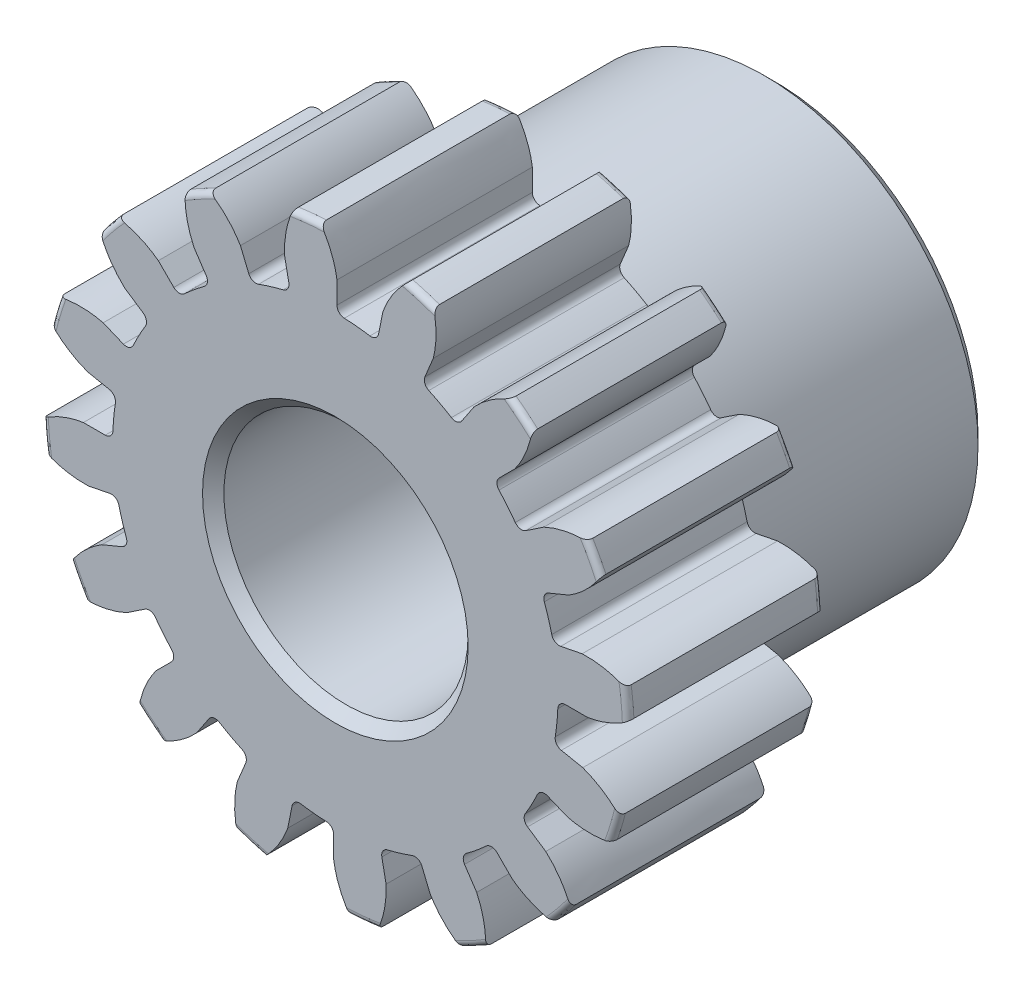
from build123d import *

# Parameters (mm, degrees)
SKETCH1_R                = 9.525
BOSS_EXTRUDE1_DEPTH      = 6.35
SKETCH2_W                = 7.9375
SKETCH2_H                = 6.9453125
FILLET2_R                = 0.1905
CUT_EXTRUDE1_DEPTH       = 15.2875
FILLET1_R                = 0.249115136
CIRPATTERN1_COUNT        = 16
FILLET1_OF_CIRPATTERN1_R = 0.249115136
SKETCH5_R                = 3.96875
CUT_EXTRUDE2_DEPTH       = 15.2875
CHAMFER1_SIZE            = 0.347265625


with BuildPart() as part:
    # Sketch1 → Boss-Extrude1 (new body)
    with BuildSketch(Plane.XY):
        Circle(SKETCH1_R)
    extrude(amount=-BOSS_EXTRUDE1_DEPTH)

    # Sketch2 → Revolve1 (revolve)
    with BuildSketch(Plane(origin=(0, 0, 0), x_dir=(0, 0, -1), z_dir=(1, 0, 0))):
        with Locations((10.31875, 3.47265625)):
            Rectangle(SKETCH2_W, SKETCH2_H)
    revolve(axis=Axis((0, 0, -6.35), (0, 0, -1)))

    # Fillet2
    fillet2_edges = [part.edges().sort_by_distance(p)[0] for p in [
        (-9.525, 0, 0),
        (-9.525, 0, -6.35),
        (0, -6.9453125, -6.35),
    ]]
    fillet(fillet2_edges, radius=FILLET2_R)

    # Sketch4 → Cut-Extrude1 (cut, through all)
    with BuildSketch(Plane.XY):
        with BuildLine():
            Line((0.053219182, 8.188613433), (0.053219182, 7.234737086))
            ThreePointArc((0.053219182, 7.234737086), (0.709149079, 7.200094483), (1.35923386, 7.106105565))
            Line((1.35923386, 7.106105565), (1.545326334, 8.04165336))
            add(Edge.make_bspline(
                [(2.643907833, 9.507053518), (1.85917452, 8.908179544), (1.545326334, 8.04165336)],
                knots=[0, 0, 0, 1, 1, 1], degree=2))
            ThreePointArc((2.643907833, 9.507053518), (0.967219956, 9.8203259), (-0.738367235, 9.84017932))
            add(Edge.make_bspline(
                [(-0.738367235, 9.84017932), (-0.085547209, 9.099718367), (0.053219182, 8.188613433)],
                knots=[0, 0, 0, 1, 1, 1], degree=2))
        make_face()
    cut_extrude1 = extrude(amount=-CUT_EXTRUDE1_DEPTH, mode=Mode.SUBTRACT)

    # Fillet1
    fillet1_edges = [part.edges().sort_by_distance(p)[0] for p in [
        (1.35923386, 7.106105565, -3.175),
        (0.053219182, 7.234737086, -3.175),
    ]]
    fillet(fillet1_edges, radius=FILLET1_R)

    # CirPattern1: Cut-Extrude1 ×16 about axis
    cirpattern1_axis = Axis((0, 0, -6.35), (0, 0, 1))
    for i in range(1, CIRPATTERN1_COUNT):
        add(cut_extrude1.rotate(cirpattern1_axis, i * 360 / CIRPATTERN1_COUNT), mode=Mode.SUBTRACT)

    # Fillet1 of CirPattern1
    fillet1_of_cirpattern1_edges = [part.edges().sort_by_distance(p)[0] for p in [
        (-1.463620525, 7.085341766, -3.175),
        (-2.719445907, 6.704391616, -3.175),
        (-4.063651953, 5.985898912, -3.175),
        (-5.078100009, 5.153363298, -3.175),
        (-6.045029208, 3.975157212, -3.175),
        (-6.663659417, 2.817782133, -3.175),
        (-7.106105565, 1.35923386, -3.175),
        (-7.234737086, 0.053219182, -3.175),
        (-7.085341766, -1.463620525, -3.175),
        (-6.704391616, -2.719445907, -3.175),
        (-5.985898912, -4.063651953, -3.175),
        (-5.153363298, -5.078100009, -3.175),
        (-3.975157212, -6.045029208, -3.175),
        (-2.817782133, -6.663659417, -3.175),
        (-1.35923386, -7.106105565, -3.175),
        (-0.053219182, -7.234737086, -3.175),
        (1.463620525, -7.085341766, -3.175),
        (2.719445907, -6.704391616, -3.175),
        (4.063651953, -5.985898912, -3.175),
        (5.078100009, -5.153363298, -3.175),
        (6.045029208, -3.975157212, -3.175),
        (6.663659417, -2.817782133, -3.175),
        (7.106105565, -1.35923386, -3.175),
        (7.234737086, -0.053219182, -3.175),
        (7.085341766, 1.463620525, -3.175),
        (6.704391616, 2.719445907, -3.175),
        (5.985898912, 4.063651953, -3.175),
        (5.153363298, 5.078100009, -3.175),
        (3.975157212, 6.045029208, -3.175),
        (2.817782133, 6.663659417, -3.175),
    ]]
    fillet(fillet1_of_cirpattern1_edges, radius=FILLET1_OF_CIRPATTERN1_R)

    # Sketch5 → Cut-Extrude2 (cut, through all)
    with BuildSketch(Plane.XY):
        Circle(SKETCH5_R)
    extrude(amount=-CUT_EXTRUDE2_DEPTH, mode=Mode.SUBTRACT)

    # Chamfer1
    chamfer1_edges = [part.edges().sort_by_distance(p)[0] for p in [
        (0, -6.9453125, -14.2875),
        (-3.96875, 0, -14.2875),
        (-3.96875, 0, 0),
    ]]
    chamfer(chamfer1_edges, length=CHAMFER1_SIZE)


solid = part.part
